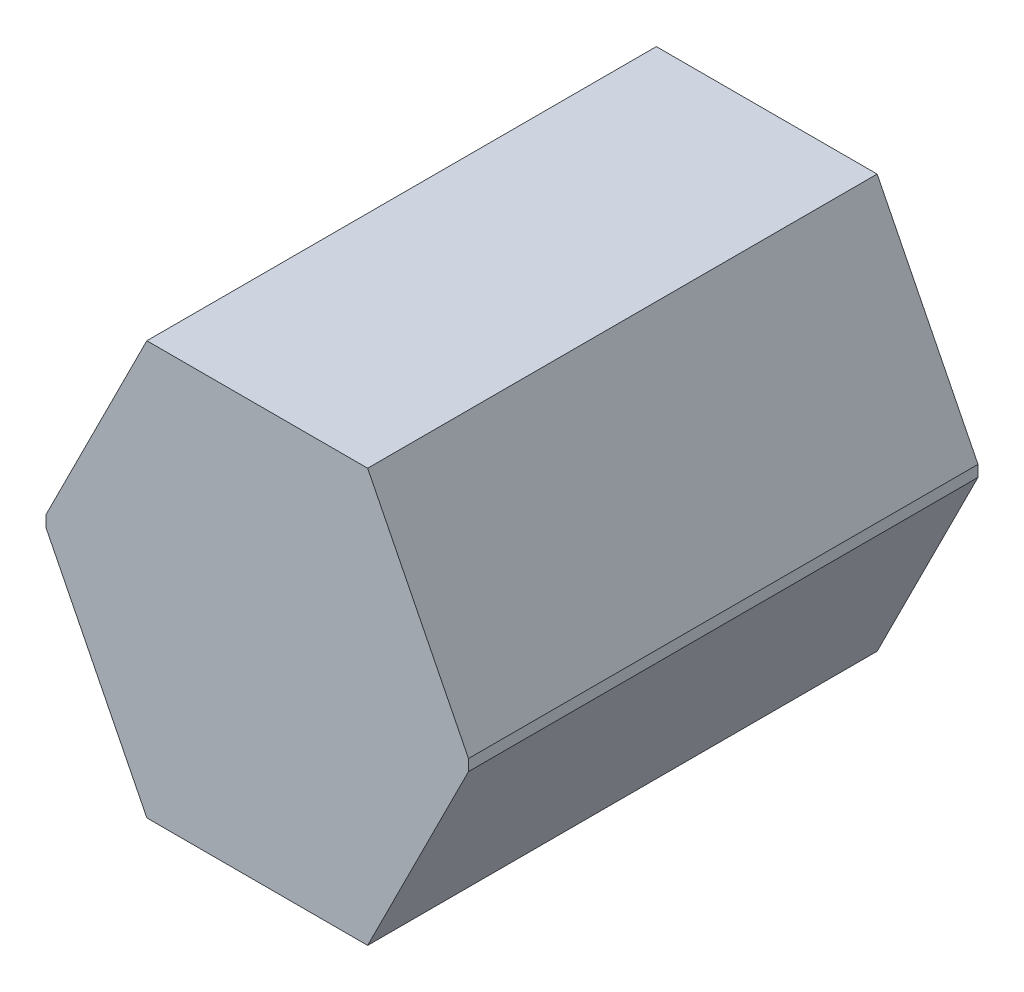
from build123d import *

# Parameters (mm, degrees)
AUFSATZ_LINEAR_AUSTRAGEN1_DEPTH = 450


with BuildPart() as part:
    # Skizze1 → Aufsatz-Linear austragen1 (new body)
    with BuildSketch(Plane.XY):
        Polygon((-97.5, 182.5), (97.5, 182.5), (186.578619899, 5), (186.578619899, -5), (97.5, -182.5), (-97.5, -182.5), (-186.578619899, -5), (-186.578619899, 5), align=None)
    extrude(amount=AUFSATZ_LINEAR_AUSTRAGEN1_DEPTH)


solid = part.part
